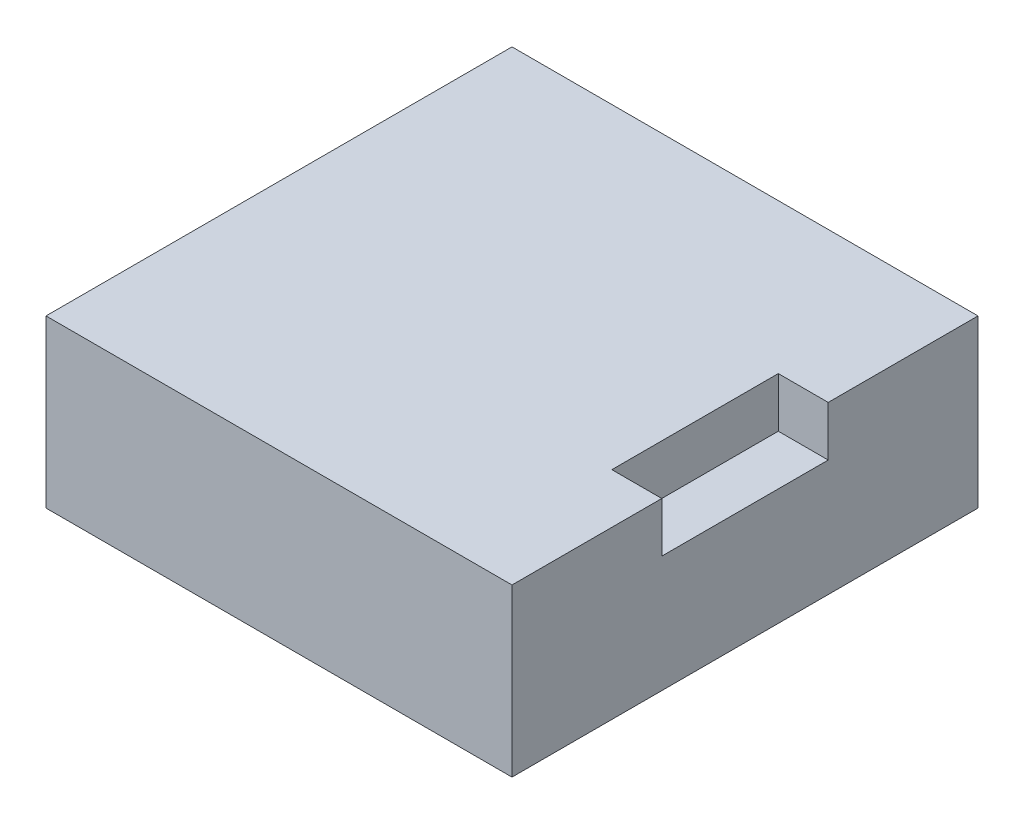
from build123d import *

# Parameters (mm, degrees)
SKETCH1_W           = 28
SKETCH1_H           = 28
BOSS_EXTRUDE1_DEPTH = 5
SKETCH2_W           = 3
SKETCH2_H           = 3
CUT_EXTRUDE1_DEPTH  = 5


with BuildPart() as part:
    # Sketch1 → Boss-Extrude1 (new body, symmetric)
    with BuildSketch(Plane(origin=(0, 0, 0), x_dir=(1, 0, 0), z_dir=(0, 1, 0))):
        Rectangle(SKETCH1_W, SKETCH1_H)
    extrude(amount=BOSS_EXTRUDE1_DEPTH, both=True)

    # Sketch2 → Cut-Extrude1 (cut, symmetric)
    with BuildSketch(Plane.XY):
        with Locations((12.5, 3.5)):
            Rectangle(SKETCH2_W, SKETCH2_H)
    extrude(amount=CUT_EXTRUDE1_DEPTH, both=True, mode=Mode.SUBTRACT)


solid = part.part
